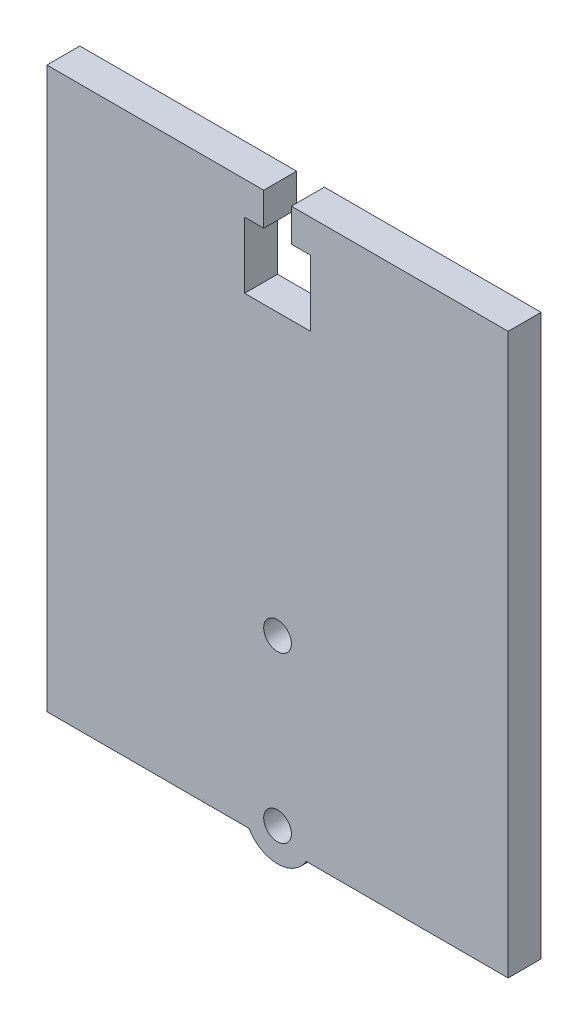
from build123d import *

# Parameters (mm, degrees)
SKETCH1_W           = 70
SKETCH1_H           = 85
BOSS_EXTRUDE1_DEPTH = 5
SKETCH2_R           = 2.1
CUT_EXTRUDE1_DEPTH  = 5
BOSS_EXTRUDE2_DEPTH = 5


with BuildPart() as part:
    # Sketch1 → Boss-Extrude1 (new body)
    with BuildSketch(Plane.XY):
        Rectangle(SKETCH1_W, SKETCH1_H)
    extrude(amount=BOSS_EXTRUDE1_DEPTH)

    # Sketch2 → Cut-Extrude1 (cut)
    with BuildSketch(Plane.XY.offset(5)):
        with Locations((0, -15)):
            Circle(SKETCH2_R)
        with Locations((0, -40)):
            Circle(SKETCH2_R)
        Polygon((2.1, 42.5), (2.1, 37.5), (5, 37.5), (5, 27.5), (-5, 27.5), (-5, 37.5), (-2.1, 37.5), (-2.1, 42.5), align=None)
    extrude(amount=-CUT_EXTRUDE1_DEPTH, mode=Mode.SUBTRACT)

    # Sketch3 → Boss-Extrude2 (add)
    with BuildSketch(Plane.XY.offset(5)):
        with BuildLine():
            Line((-4.330127019, -42.5), (4.330127019, -42.5))
            ThreePointArc((4.330127019, -42.5), (0, -45), (-4.330127019, -42.5))
        make_face()
    extrude(amount=-BOSS_EXTRUDE2_DEPTH)


solid = part.part
